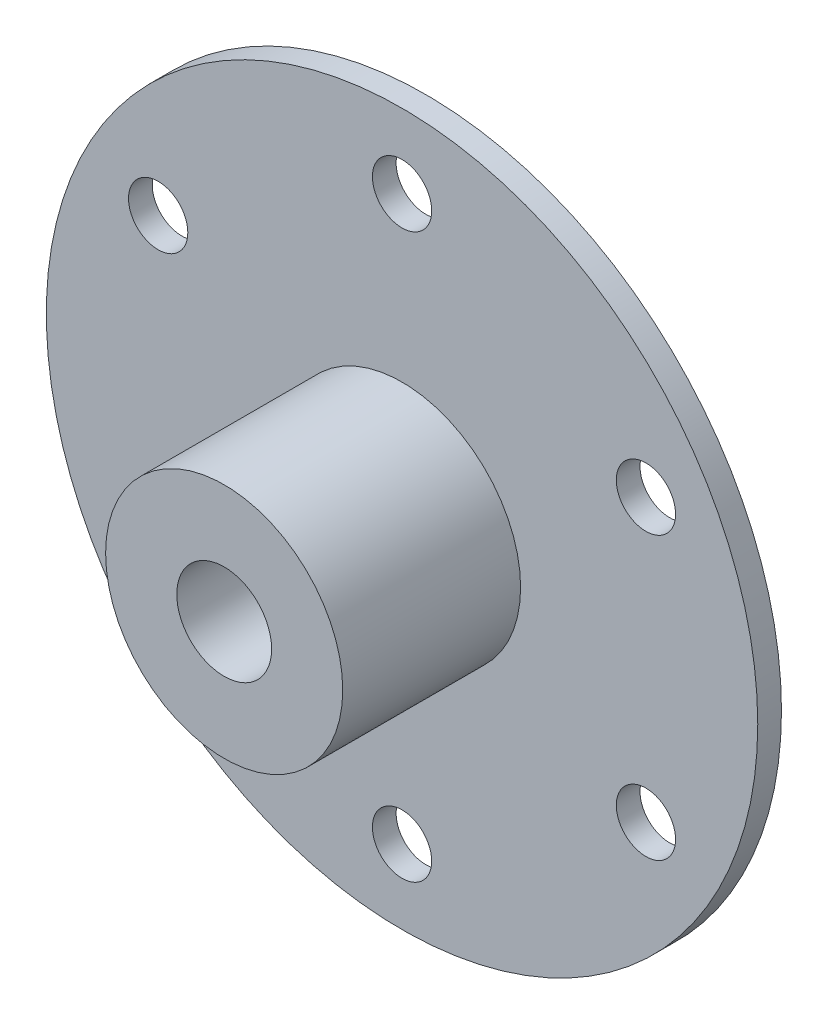
from build123d import *

# Parameters (mm, degrees)
SKETCH1_R           = 30
SKETCH1_R_2         = 2.5
BOSS_EXTRUDE1_DEPTH = 2
SKETCH2_R           = 10
SKETCH2_R_2         = 4
BOSS_EXTRUDE2_DEPTH = 15


with BuildPart() as part:
    # Sketch1 → Boss-Extrude1 (new body)
    with BuildSketch(Plane.XY):
        Circle(SKETCH1_R)
        with Locations((0, 23.75)):
            Circle(SKETCH1_R_2, mode=Mode.SUBTRACT)
        with Locations((20.56810334, 11.875)):
            Circle(SKETCH1_R_2, mode=Mode.SUBTRACT)
        with Locations((20.56810334, -11.875)):
            Circle(SKETCH1_R_2, mode=Mode.SUBTRACT)
        with Locations((0, -23.75)):
            Circle(SKETCH1_R_2, mode=Mode.SUBTRACT)
        with Locations((-20.56810334, -11.875)):
            Circle(SKETCH1_R_2, mode=Mode.SUBTRACT)
        with Locations((-20.56810334, 11.875)):
            Circle(SKETCH1_R_2, mode=Mode.SUBTRACT)
    extrude(amount=BOSS_EXTRUDE1_DEPTH)

    # Sketch2 → Boss-Extrude2 (add)
    with BuildSketch(Plane.XY.offset(2)):
        Circle(SKETCH2_R)
        Circle(SKETCH2_R_2, mode=Mode.SUBTRACT)
    extrude(amount=BOSS_EXTRUDE2_DEPTH)


solid = part.part
